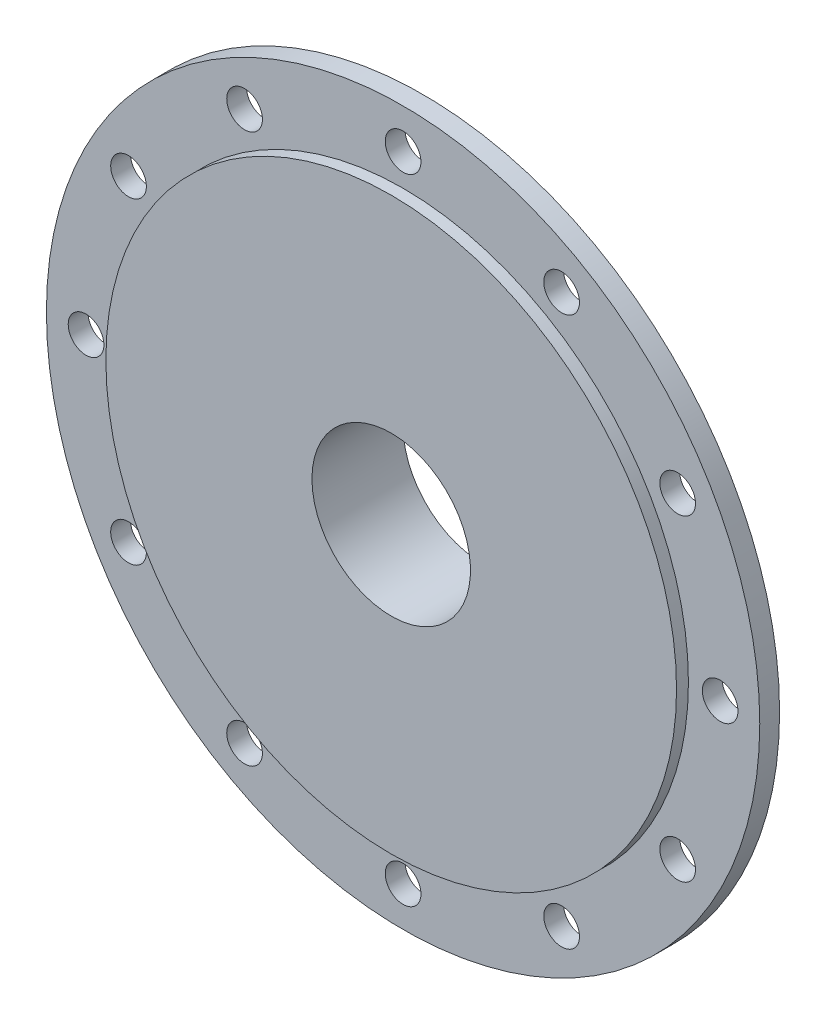
from build123d import *

# Parameters (mm, degrees)
IZIM2_R               = 20
KES_EKSTR_ZYON1_DEPTH = 130.340635533
FEDER6_REACH          = 131.341
IZIM3_WALL_W          = 307.641360504
IZIM3_WALL_H          = 5
FEDER7_REACH          = 131.341
IZIM4_WALL_W          = 307.641360504
IZIM4_WALL_H          = 5
KES_EKSTR_ZYON2_REACH = 130.16
IZIM5_R               = 4.5


with BuildPart() as part:
    # Çizim1 → Döndür1 (revolve)
    with BuildSketch(Plane(origin=(0, 0, 0), x_dir=(0, 0, -1), z_dir=(1, 0, 0)), mode=Mode.PRIVATE) as d_nd_r1_sk:
        Polygon((0, 20), (0, 72), (3, 72), (3, 90), (8, 90), (8, 67.5), (5, 67.5), (5, 25), (23, 25), (23, 0), (0, 0), align=None)
    revolve(d_nd_r1_sk.sketch.rotate(Axis((0, 0, 0), (0, 0, 1)), 90), axis=Axis((0, 0, 0), (0, 0, 1)))

    # Çizim2 → Kes-Ekstrüzyon1 (cut, through all)
    with BuildSketch(Plane(origin=(0, 0, -23), x_dir=(-1, 0, 0), z_dir=(0, 0, -1))):
        Circle(IZIM2_R)
    extrude(amount=-KES_EKSTR_ZYON1_DEPTH, mode=Mode.SUBTRACT)

    # Çizim3 wall → Feder6 (add, up to next)
    with BuildSketch(Plane(origin=(0, 45.25, -15.5), x_dir=(0, 0.947613186704, 0.319420175294), z_dir=(0, -0.319420175294, 0.947613186704)), mode=Mode.PRIVATE) as feder6_sk1:
        Rectangle(IZIM3_WALL_W, IZIM3_WALL_H)
    feder6_tool1 = extrude(feder6_sk1.sketch, amount=FEDER6_REACH, mode=Mode.PRIVATE) - part.part
    feder6 = feder6_tool1.solids().sort_by_distance((0, 45.25, -15.5))[0]
    add(feder6)

    # Aynalama1: Feder6 across plane
    add(feder6.mirror(Plane.ZX))

    # Çizim4 wall → Feder7 (add, up to next)
    with BuildSketch(Plane(origin=(-45.25, 0, -15.5), x_dir=(-0.947613186704, 0, 0.319420175294), z_dir=(0.319420175294, 0, 0.947613186704)), mode=Mode.PRIVATE) as feder7_sk1:
        Rectangle(IZIM4_WALL_W, IZIM4_WALL_H)
    feder7_tool1 = extrude(feder7_sk1.sketch, amount=FEDER7_REACH, mode=Mode.PRIVATE) - part.part
    feder7 = feder7_tool1.solids().sort_by_distance((-45.25, 0, -15.5))[0]
    add(feder7)

    # Aynalama2: Feder7 across plane
    add(feder7.mirror(Plane(origin=(0, 0, 0), x_dir=(0, 0, 1), z_dir=(1, 0, 0))))

    # Çizim5 → Kes-Ekstrüzyon2 (cut, up to next)
    with BuildSketch(Plane(origin=(0, 0, -8), x_dir=(-1, 0, 0), z_dir=(0, 0, -1)), mode=Mode.PRIVATE) as kes_ekstr_zyon2_sk1:
        with Locations((0, 80)):
            Circle(IZIM5_R)
    kes_ekstr_zyon2_tool1 = extrude(kes_ekstr_zyon2_sk1.sketch, amount=-KES_EKSTR_ZYON2_REACH, mode=Mode.PRIVATE) & part.part
    # Çizim5 → Kes-Ekstrüzyon2 (cut, up to next)
    with BuildSketch(Plane(origin=(0, 0, -8), x_dir=(-1, 0, 0), z_dir=(0, 0, -1)), mode=Mode.PRIVATE) as kes_ekstr_zyon2_sk2:
        with Locations((40, 69.282032303)):
            Circle(IZIM5_R)
    kes_ekstr_zyon2_tool2 = extrude(kes_ekstr_zyon2_sk2.sketch, amount=-KES_EKSTR_ZYON2_REACH, mode=Mode.PRIVATE) & part.part
    # Çizim5 → Kes-Ekstrüzyon2 (cut, up to next)
    with BuildSketch(Plane(origin=(0, 0, -8), x_dir=(-1, 0, 0), z_dir=(0, 0, -1)), mode=Mode.PRIVATE) as kes_ekstr_zyon2_sk3:
        with Locations((69.282032303, 40)):
            Circle(IZIM5_R)
    kes_ekstr_zyon2_tool3 = extrude(kes_ekstr_zyon2_sk3.sketch, amount=-KES_EKSTR_ZYON2_REACH, mode=Mode.PRIVATE) & part.part
    # Çizim5 → Kes-Ekstrüzyon2 (cut, up to next)
    with BuildSketch(Plane(origin=(0, 0, -8), x_dir=(-1, 0, 0), z_dir=(0, 0, -1)), mode=Mode.PRIVATE) as kes_ekstr_zyon2_sk4:
        with Locations((80, 0)):
            Circle(IZIM5_R)
    kes_ekstr_zyon2_tool4 = extrude(kes_ekstr_zyon2_sk4.sketch, amount=-KES_EKSTR_ZYON2_REACH, mode=Mode.PRIVATE) & part.part
    # Çizim5 → Kes-Ekstrüzyon2 (cut, up to next)
    with BuildSketch(Plane(origin=(0, 0, -8), x_dir=(-1, 0, 0), z_dir=(0, 0, -1)), mode=Mode.PRIVATE) as kes_ekstr_zyon2_sk5:
        with Locations((69.282032303, -40)):
            Circle(IZIM5_R)
    kes_ekstr_zyon2_tool5 = extrude(kes_ekstr_zyon2_sk5.sketch, amount=-KES_EKSTR_ZYON2_REACH, mode=Mode.PRIVATE) & part.part
    # Çizim5 → Kes-Ekstrüzyon2 (cut, up to next)
    with BuildSketch(Plane(origin=(0, 0, -8), x_dir=(-1, 0, 0), z_dir=(0, 0, -1)), mode=Mode.PRIVATE) as kes_ekstr_zyon2_sk6:
        with Locations((40, -69.282032303)):
            Circle(IZIM5_R)
    kes_ekstr_zyon2_tool6 = extrude(kes_ekstr_zyon2_sk6.sketch, amount=-KES_EKSTR_ZYON2_REACH, mode=Mode.PRIVATE) & part.part
    # Çizim5 → Kes-Ekstrüzyon2 (cut, up to next)
    with BuildSketch(Plane(origin=(0, 0, -8), x_dir=(-1, 0, 0), z_dir=(0, 0, -1)), mode=Mode.PRIVATE) as kes_ekstr_zyon2_sk7:
        with Locations((0, -80)):
            Circle(IZIM5_R)
    kes_ekstr_zyon2_tool7 = extrude(kes_ekstr_zyon2_sk7.sketch, amount=-KES_EKSTR_ZYON2_REACH, mode=Mode.PRIVATE) & part.part
    # Çizim5 → Kes-Ekstrüzyon2 (cut, up to next)
    with BuildSketch(Plane(origin=(0, 0, -8), x_dir=(-1, 0, 0), z_dir=(0, 0, -1)), mode=Mode.PRIVATE) as kes_ekstr_zyon2_sk8:
        with Locations((-40, -69.282032303)):
            Circle(IZIM5_R)
    kes_ekstr_zyon2_tool8 = extrude(kes_ekstr_zyon2_sk8.sketch, amount=-KES_EKSTR_ZYON2_REACH, mode=Mode.PRIVATE) & part.part
    # Çizim5 → Kes-Ekstrüzyon2 (cut, up to next)
    with BuildSketch(Plane(origin=(0, 0, -8), x_dir=(-1, 0, 0), z_dir=(0, 0, -1)), mode=Mode.PRIVATE) as kes_ekstr_zyon2_sk9:
        with Locations((-69.282032303, -40)):
            Circle(IZIM5_R)
    kes_ekstr_zyon2_tool9 = extrude(kes_ekstr_zyon2_sk9.sketch, amount=-KES_EKSTR_ZYON2_REACH, mode=Mode.PRIVATE) & part.part
    # Çizim5 → Kes-Ekstrüzyon2 (cut, up to next)
    with BuildSketch(Plane(origin=(0, 0, -8), x_dir=(-1, 0, 0), z_dir=(0, 0, -1)), mode=Mode.PRIVATE) as kes_ekstr_zyon2_sk10:
        with Locations((-80, 0)):
            Circle(IZIM5_R)
    kes_ekstr_zyon2_tool10 = extrude(kes_ekstr_zyon2_sk10.sketch, amount=-KES_EKSTR_ZYON2_REACH, mode=Mode.PRIVATE) & part.part
    # Çizim5 → Kes-Ekstrüzyon2 (cut, up to next)
    with BuildSketch(Plane(origin=(0, 0, -8), x_dir=(-1, 0, 0), z_dir=(0, 0, -1)), mode=Mode.PRIVATE) as kes_ekstr_zyon2_sk11:
        with Locations((-69.282032303, 40)):
            Circle(IZIM5_R)
    kes_ekstr_zyon2_tool11 = extrude(kes_ekstr_zyon2_sk11.sketch, amount=-KES_EKSTR_ZYON2_REACH, mode=Mode.PRIVATE) & part.part
    # Çizim5 → Kes-Ekstrüzyon2 (cut, up to next)
    with BuildSketch(Plane(origin=(0, 0, -8), x_dir=(-1, 0, 0), z_dir=(0, 0, -1)), mode=Mode.PRIVATE) as kes_ekstr_zyon2_sk12:
        with Locations((-40, 69.282032303)):
            Circle(IZIM5_R)
    kes_ekstr_zyon2_tool12 = extrude(kes_ekstr_zyon2_sk12.sketch, amount=-KES_EKSTR_ZYON2_REACH, mode=Mode.PRIVATE) & part.part
    add(kes_ekstr_zyon2_tool1.solids().sort_by_distance((0, 80, -8))[0], mode=Mode.SUBTRACT)
    add(kes_ekstr_zyon2_tool2.solids().sort_by_distance((-40, 69.282032, -8))[0], mode=Mode.SUBTRACT)
    add(kes_ekstr_zyon2_tool3.solids().sort_by_distance((-69.282032, 40, -8))[0], mode=Mode.SUBTRACT)
    add(kes_ekstr_zyon2_tool4.solids().sort_by_distance((-80, 0, -8))[0], mode=Mode.SUBTRACT)
    add(kes_ekstr_zyon2_tool5.solids().sort_by_distance((-69.282032, -40, -8))[0], mode=Mode.SUBTRACT)
    add(kes_ekstr_zyon2_tool6.solids().sort_by_distance((-40, -69.282032, -8))[0], mode=Mode.SUBTRACT)
    add(kes_ekstr_zyon2_tool7.solids().sort_by_distance((0, -80, -8))[0], mode=Mode.SUBTRACT)
    add(kes_ekstr_zyon2_tool8.solids().sort_by_distance((40, -69.282032, -8))[0], mode=Mode.SUBTRACT)
    add(kes_ekstr_zyon2_tool9.solids().sort_by_distance((69.282032, -40, -8))[0], mode=Mode.SUBTRACT)
    add(kes_ekstr_zyon2_tool10.solids().sort_by_distance((80, 0, -8))[0], mode=Mode.SUBTRACT)
    add(kes_ekstr_zyon2_tool11.solids().sort_by_distance((69.282032, 40, -8))[0], mode=Mode.SUBTRACT)
    add(kes_ekstr_zyon2_tool12.solids().sort_by_distance((40, 69.282032, -8))[0], mode=Mode.SUBTRACT)


solid = part.part
